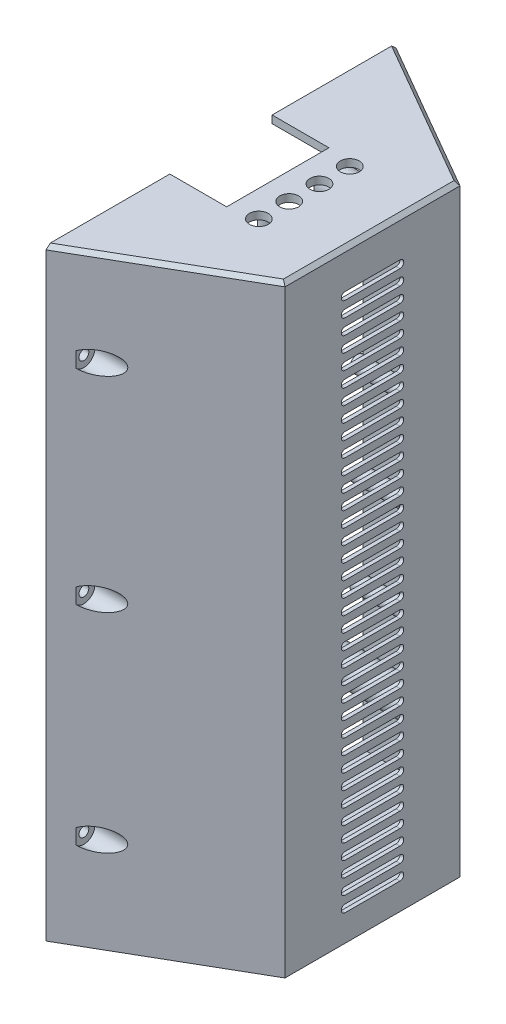
from build123d import *

# Parameters (mm, degrees)
BOSS_EXTRUDE5_DEPTH  = 155
BOSS_EXTRUDE6_DEPTH  = 2
BOSS_EXTRUDE7_DEPTH  = 155
SKETCH10_R           = 2
SKETCH10_R_2         = 0.9
BOSS_EXTRUDE9_DEPTH  = 13
CUT_EXTRUDE1_DEPTH   = 2
LPATTERN1_COUNT      = 36
LPATTERN1_PITCH      = 4
BOSS_EXTRUDE10_DEPTH = 2
CHAMFER2_SIZE        = 1
BOSS_EXTRUDE12_REACH = 42
SKETCH16_R           = 4
SKETCH17_R           = 1.3
CUT_EXTRUDE2_DEPTH   = 10
SKETCH18_R           = 1.3
CUT_EXTRUDE3_DEPTH   = 10
SKETCH19_R           = 1.3
CUT_EXTRUDE4_DEPTH   = 10
SKETCH20_R           = 1.3
CUT_EXTRUDE5_DEPTH   = 10
SKETCH21_W           = 30
SKETCH21_H           = 27
CUT_EXTRUDE6_DEPTH   = 10
SKETCH22_R           = 2
SKETCH22_R_2         = 0.9
BOSS_EXTRUDE13_DEPTH = 10
SKETCH23_R           = 1.3
CUT_EXTRUDE7_DEPTH   = 35
SKETCH25_R           = 2.5
CUT_EXTRUDE9_DEPTH   = 2
SKETCH29_R           = 2.9
CUT_EXTRUDE10_DEPTH  = 10


with BuildPart() as part:
    # Sketch4 → Boss-Extrude5 (new body)
    with BuildSketch(Plane(origin=(0, 0, 0), x_dir=(1, 0, 0), z_dir=(0, 1, 0))):
        Polygon((0, 46.188021535), (0, 45.033320997), (39, 22.516660498), (39, -22.516660498), (0, -45.033320997), (0, -46.188021535), (40, -23.094010768), (40, 23.094010768), align=None)
    extrude(amount=BOSS_EXTRUDE5_DEPTH)

    # Sketch5 → Boss-Extrude6 (add)
    with BuildSketch(Plane.XZ):
        Polygon((0, 46.188021535), (40, 23.094010768), (40, -23.094010768), (0, -46.188021535), align=None)
    extrude(amount=BOSS_EXTRUDE6_DEPTH)

    # Sketch6 → Boss-Extrude7 (add)
    with BuildSketch(Plane(origin=(0, 0, 0), x_dir=(1, 0, 0), z_dir=(0, 1, 0))):
        Polygon((0, -45.033320997), (0, -37.533320997), (12.990381057, -37.533320997), align=None)
        Polygon((0, 45.033320997), (0, 37.533320997), (12.990381057, 37.533320997), align=None)
    extrude(amount=BOSS_EXTRUDE7_DEPTH)

    # Sketch10 → Boss-Extrude9 (add)
    with BuildSketch(Plane.ZY.offset(-39)):
        with Locations((10, 115)):
            Circle(SKETCH10_R)
        with Locations((10, 115)):
            Circle(SKETCH10_R_2, mode=Mode.SUBTRACT)
        with Locations((-10, 115)):
            Circle(SKETCH10_R)
        with Locations((-10, 115)):
            Circle(SKETCH10_R_2, mode=Mode.SUBTRACT)
        with Locations((-10, 90)):
            Circle(SKETCH10_R)
        with Locations((-10, 90)):
            Circle(SKETCH10_R_2, mode=Mode.SUBTRACT)
        with Locations((10, 90)):
            Circle(SKETCH10_R)
        with Locations((10, 90)):
            Circle(SKETCH10_R_2, mode=Mode.SUBTRACT)
        with Locations((-10, 65)):
            Circle(SKETCH10_R)
        with Locations((-10, 65)):
            Circle(SKETCH10_R_2, mode=Mode.SUBTRACT)
        with Locations((10, 65)):
            Circle(SKETCH10_R)
        with Locations((10, 65)):
            Circle(SKETCH10_R_2, mode=Mode.SUBTRACT)
    extrude(amount=BOSS_EXTRUDE9_DEPTH)

    # Sketch11 → Cut-Extrude1 (cut)
    with BuildSketch(Plane.ZY.offset(-39)):
        with BuildLine():
            Line((-7.25, 147), (0, 147))
            Line((0, 147), (7.25, 147))
            ThreePointArc((7.25, 147), (8.25, 146), (7.25, 145))
            Line((7.25, 145), (0, 145))
            Line((0, 145), (-7.25, 145))
            ThreePointArc((-7.25, 145), (-8.25, 146), (-7.25, 147))
        make_face()
    cut_extrude1 = extrude(amount=-CUT_EXTRUDE1_DEPTH, mode=Mode.SUBTRACT)

    # LPattern1: Cut-Extrude1 ×36
    with Locations(*[(0, -i * LPATTERN1_PITCH, 0) for i in range(1, LPATTERN1_COUNT)]):
        add(cut_extrude1, mode=Mode.SUBTRACT)

    # Sketch12 → Boss-Extrude10 (add)
    with BuildSketch(Plane(origin=(0, 155, 0), x_dir=(1, 0, 0), z_dir=(0, 1, 0))):
        Polygon((0, 46.188021535), (40, 23.094010768), (40, -23.094010768), (0, -46.188021535), align=None)
    extrude(amount=BOSS_EXTRUDE10_DEPTH)

    # Chamfer2
    chamfer2_edges = [part.edges().sort_by_distance(p)[0] for p in [
        (20, 157, 34.641016151),
        (40, 157, 0),
        (20, 157, -34.641016151),
    ]]
    chamfer(chamfer2_edges, length=CHAMFER2_SIZE)


with BuildPart() as body_2:

    # Sketch16 → Boss-Extrude12 (new body, up to next)
    with BuildSketch(Plane.ZY, mode=Mode.PRIVATE) as boss_extrude12_sk1:
        with Locations((-28.5, 135)):
            Circle(SKETCH16_R)
    boss_extrude12_tool1 = extrude(boss_extrude12_sk1.sketch, amount=-BOSS_EXTRUDE12_REACH, mode=Mode.PRIVATE) - part.part
    add(boss_extrude12_tool1.solids().sort_by_distance((0, 135, -28.5))[0])
    # Sketch16 → Boss-Extrude12 (new body, up to next)
    with BuildSketch(Plane.ZY, mode=Mode.PRIVATE) as boss_extrude12_sk2:
        with Locations((22.5, 135)):
            Circle(SKETCH16_R)
    boss_extrude12_tool2 = extrude(boss_extrude12_sk2.sketch, amount=-BOSS_EXTRUDE12_REACH, mode=Mode.PRIVATE) - part.part
    add(boss_extrude12_tool2.solids().sort_by_distance((0, 135, 22.5))[0])
    # Sketch16 → Boss-Extrude12 (new body, up to next)
    with BuildSketch(Plane.ZY, mode=Mode.PRIVATE) as boss_extrude12_sk3:
        with Locations((23.5, 36.5)):
            Circle(SKETCH16_R)
    boss_extrude12_tool3 = extrude(boss_extrude12_sk3.sketch, amount=-BOSS_EXTRUDE12_REACH, mode=Mode.PRIVATE) - part.part
    add(boss_extrude12_tool3.solids().sort_by_distance((0, 36.5, 23.5))[0])
    # Sketch16 → Boss-Extrude12 (new body, up to next)
    with BuildSketch(Plane.ZY, mode=Mode.PRIVATE) as boss_extrude12_sk4:
        with Locations((-23.5, 31)):
            Circle(SKETCH16_R)
    boss_extrude12_tool4 = extrude(boss_extrude12_sk4.sketch, amount=-BOSS_EXTRUDE12_REACH, mode=Mode.PRIVATE) - part.part
    add(boss_extrude12_tool4.solids().sort_by_distance((0, 31, -23.5))[0])

    # Sketch17 → Cut-Extrude2 (cut)
    with BuildSketch(Plane.ZY):
        with Locations((-23.5, 31)):
            Circle(SKETCH17_R)
    extrude(amount=-CUT_EXTRUDE2_DEPTH, mode=Mode.SUBTRACT)

    # Sketch18 → Cut-Extrude3 (cut)
    with BuildSketch(Plane.ZY):
        with Locations((23.5, 36.5)):
            Circle(SKETCH18_R)
    extrude(amount=-CUT_EXTRUDE3_DEPTH, mode=Mode.SUBTRACT)

    # Sketch19 → Cut-Extrude4 (cut)
    with BuildSketch(Plane.ZY):
        with Locations((-28.5, 135)):
            Circle(SKETCH19_R)
    extrude(amount=-CUT_EXTRUDE4_DEPTH, mode=Mode.SUBTRACT)

    # Sketch20 → Cut-Extrude5 (cut)
    with BuildSketch(Plane.ZY):
        with Locations((22.5, 135)):
            Circle(SKETCH20_R)
    extrude(amount=-CUT_EXTRUDE5_DEPTH, mode=Mode.SUBTRACT)


with BuildPart() as part_1:
    add(part.part)

    # Sketch21 → Cut-Extrude6 (cut)
    with BuildSketch(Plane(origin=(0, 157, 0), x_dir=(1, 0, 0), z_dir=(0, 1, 0))):
        Rectangle(SKETCH21_W, SKETCH21_H)
    extrude(amount=-CUT_EXTRUDE6_DEPTH, mode=Mode.SUBTRACT)

    # Sketch22 → Boss-Extrude13 (add)
    with BuildSketch(Plane.XZ.offset(-155)):
        with Locations((8, -24.5)):
            Circle(SKETCH22_R)
        with Locations((8, -24.5)):
            Circle(SKETCH22_R_2, mode=Mode.SUBTRACT)
        with Locations((18, 5.5)):
            Circle(SKETCH22_R)
        with Locations((18, 5.5)):
            Circle(SKETCH22_R_2, mode=Mode.SUBTRACT)
    extrude(amount=BOSS_EXTRUDE13_DEPTH)

    # Sketch23 → Cut-Extrude7 (cut)
    with BuildSketch(Plane.ZY):
        with Locations((-41.188021535, 132)):
            Circle(SKETCH23_R)
        with Locations((41.188021535, 132)):
            Circle(SKETCH23_R)
        with Locations((-41.188021535, 78)):
            Circle(SKETCH23_R)
        with Locations((41.188021535, 78)):
            Circle(SKETCH23_R)
        with Locations((41.188021535, 23)):
            Circle(SKETCH23_R)
        with Locations((-41.188021535, 23)):
            Circle(SKETCH23_R)
    extrude(amount=-CUT_EXTRUDE7_DEPTH, mode=Mode.SUBTRACT)

    # Sketch25 → Cut-Extrude9 (cut)
    with BuildSketch(Plane(origin=(0, 157, 0), x_dir=(1, 0, 0), z_dir=(0, 1, 0))):
        with Locations((22, 12)):
            Circle(SKETCH25_R)
        with Locations((22, 4)):
            Circle(SKETCH25_R)
        with Locations((22, -4)):
            Circle(SKETCH25_R)
        with Locations((22, -12)):
            Circle(SKETCH25_R)
    extrude(amount=-CUT_EXTRUDE9_DEPTH, mode=Mode.SUBTRACT)

    # Sketch29 → Cut-Extrude10 (cut)
    with BuildSketch(Plane.ZY.offset(-5)):
        with Locations((-41.188021535, 132)):
            Circle(SKETCH29_R)
        with Locations((-41.188021535, 23)):
            Circle(SKETCH29_R)
        with Locations((41.188021535, 23)):
            Circle(SKETCH29_R)
        with Locations((41.188021535, 78)):
            Circle(SKETCH29_R)
        with Locations((41.188021535, 132)):
            Circle(SKETCH29_R)
        with Locations((-41.188021535, 78)):
            Circle(SKETCH29_R)
    extrude(amount=-CUT_EXTRUDE10_DEPTH, mode=Mode.SUBTRACT)


solid = Compound([body_2.part, part_1.part])
